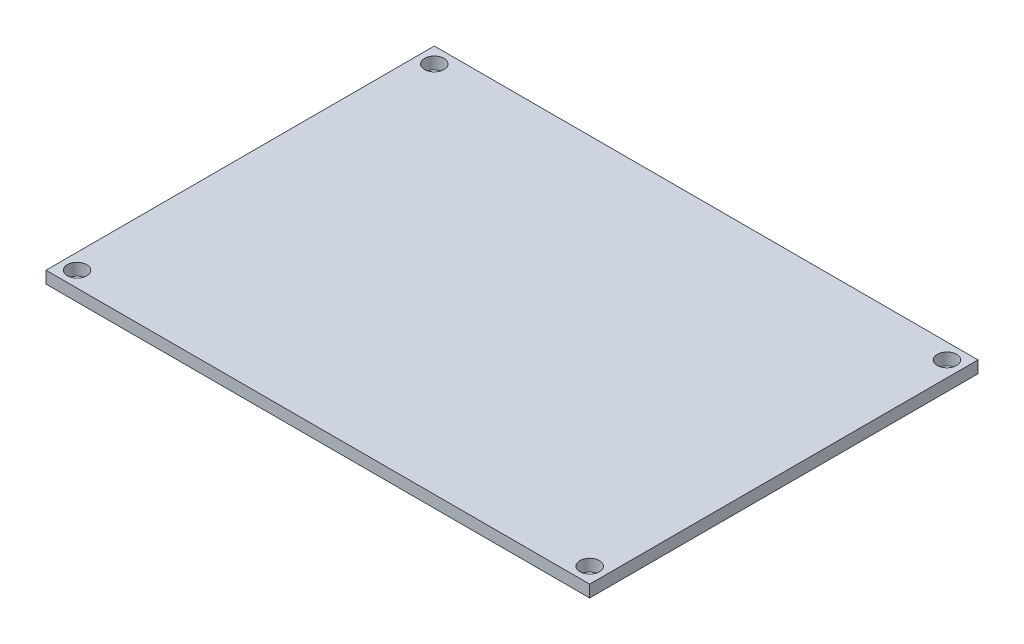
from build123d import *

# Parameters (mm, degrees)
SKETCH1_W           = 70
SKETCH1_H           = 50
SKETCH1_R           = 1.25
BOSS_EXTRUDE1_DEPTH = 0.775


with BuildPart() as part:
    # Sketch1 → Boss-Extrude1 (new body, symmetric)
    with BuildSketch(Plane(origin=(0, 0, 0), x_dir=(1, 0, 0), z_dir=(0, 1, 0))):
        Rectangle(SKETCH1_W, SKETCH1_H)
        with Locations((-33, 23)):
            Circle(SKETCH1_R, mode=Mode.SUBTRACT)
        with Locations((33, 23)):
            Circle(SKETCH1_R, mode=Mode.SUBTRACT)
        with Locations((-33, -23)):
            Circle(SKETCH1_R, mode=Mode.SUBTRACT)
        with Locations((33, -23)):
            Circle(SKETCH1_R, mode=Mode.SUBTRACT)
    extrude(amount=BOSS_EXTRUDE1_DEPTH, both=True)


solid = part.part
